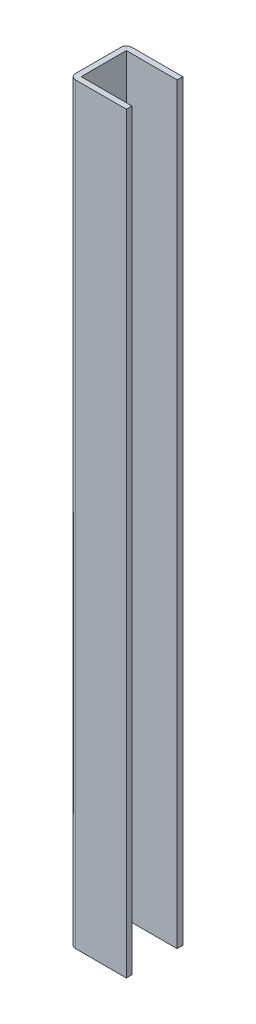
from build123d import *

# Parameters (mm, degrees)
SKETCH_1_W          = 74
SKETCH_1_H          = 24
EXTRUDE_1_DEPTH     = 400
SKETCH_2_W          = 51.146480438
SKETCH_2_H          = 44.035025014
CUT_EXTRUDE_1_DEPTH = 401


with BuildPart() as part:
    # Эскиз1 → Вытянуть-Тонкостенный1 (new body)
    with BuildSketch(Plane(origin=(0, 0, 0), x_dir=(1, 0, 0), z_dir=(0, 1, 0))):
        with BuildLine():
            Line((40, 12), (40, -12))
            ThreePointArc((40, -12), (39.121320344, -14.121320344), (37, -15))
            Line((37, -15), (-37, -15))
            ThreePointArc((-37, -15), (-39.121320344, -14.121320344), (-40, -12))
            Line((-40, -12), (-40, 12))
            ThreePointArc((-40, 12), (-39.121320344, 14.121320344), (-37, 15))
            Line((-37, 15), (37, 15))
            ThreePointArc((37, 15), (39.121320344, 14.121320344), (40, 12))
        make_face()
        Rectangle(SKETCH_1_W, SKETCH_1_H, mode=Mode.SUBTRACT)
    extrude(amount=EXTRUDE_1_DEPTH)

    # Эскиз2 → Вырез-Вытянуть1 (cut, through all)
    with BuildSketch(Plane(origin=(0, 400, 0), x_dir=(1, 0, 0), z_dir=(0, 1, 0))):
        with Locations((15.573240219, -1.044738789)):
            Rectangle(SKETCH_2_W, SKETCH_2_H)
    extrude(amount=-CUT_EXTRUDE_1_DEPTH, mode=Mode.SUBTRACT)


solid = part.part
